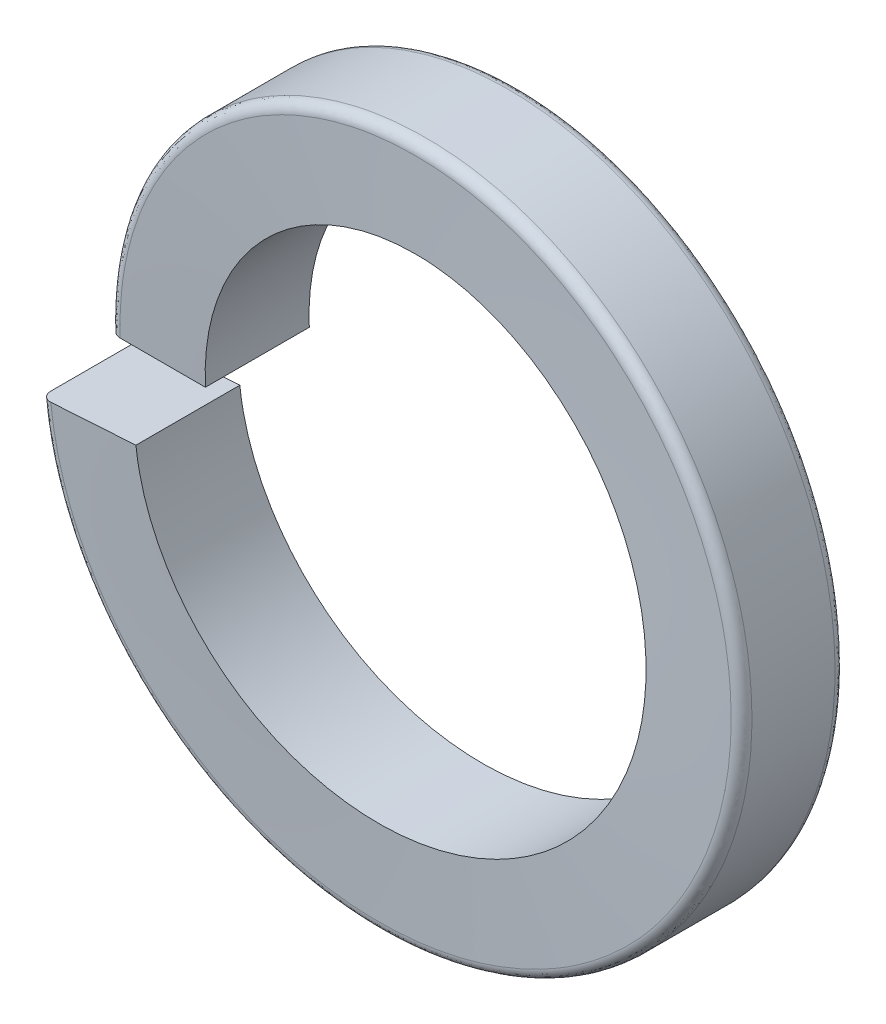
from build123d import *

# Parameters (mm, degrees)
SWEEP3_PITCH       = 0.8636
SWEEP3_HEIGHT      = 0.854964
SWEEP3_RADIUS      = 3.4925
SWEEP3_START_ANGLE = -180
SKETCH2_W          = 1.1684
SKETCH2_H          = 1.27
FILLET1_R          = 0.127


with BuildPart() as part:
    # Sweep3: sweep along a helix
    with BuildLine() as sweep3_path:
        add(Helix(SWEEP3_PITCH, SWEEP3_HEIGHT, SWEEP3_RADIUS, center=(0, 0, 0), direction=(0, 0, 1), lefthand=True, mode=Mode.PRIVATE).rotate(Axis((0, 0, 0), (0, 0, 1)), SWEEP3_START_ANGLE))
    # Sketch2 → Sweep3 (sweep)
    with BuildSketch(Plane(origin=(0, 0, 0), x_dir=(1, 0, 0), z_dir=(0, 1, 0))):
        with Locations((3.492232136, -0.431799383)):
            Rectangle(SKETCH2_W, SKETCH2_H)
    sweep(path=sweep3_path.line, is_frenet=True)

    # Fillet1
    fillet1_edges = [part.edges().sort_by_distance(p)[0] for p in [
        (4.07441676, 0.128043705, -0.207518617),
        (4.07441676, 0.128043705, 1.062481383),
    ]]
    fillet(fillet1_edges, radius=FILLET1_R)


solid = part.part
